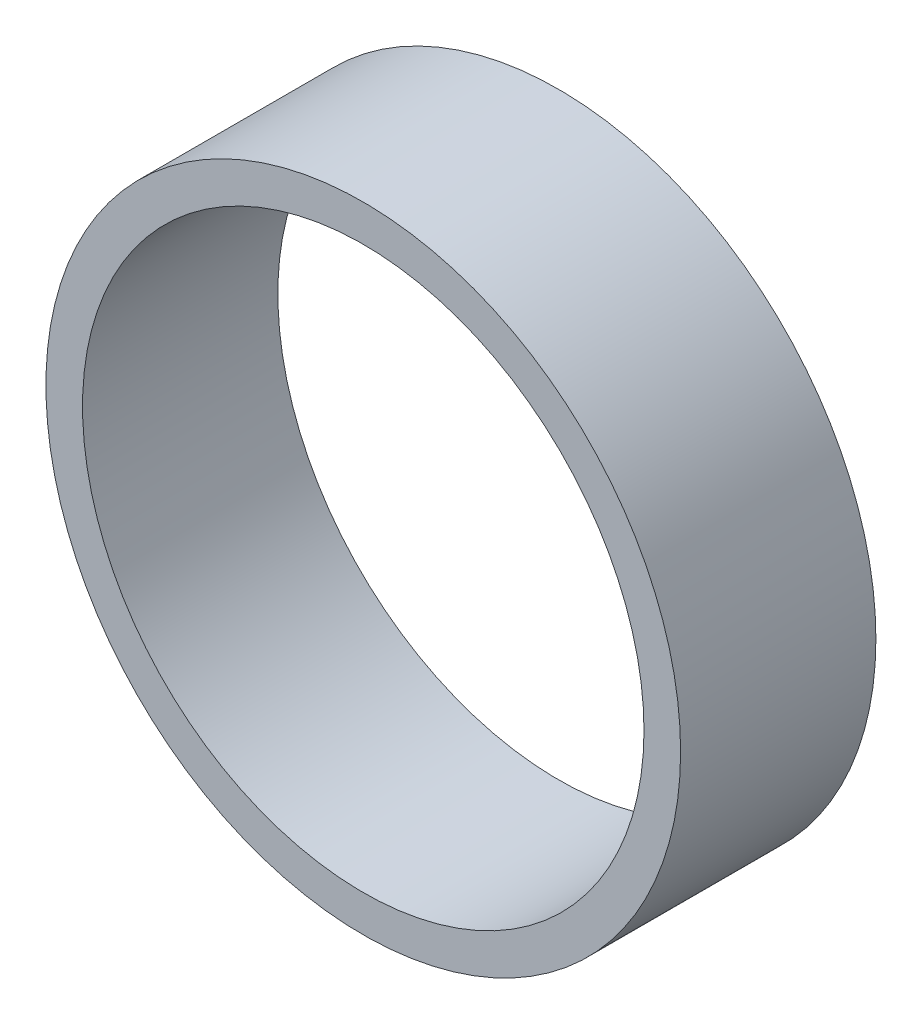
from build123d import *

# Parameters (mm, degrees)
SKETCH_1_R      = 13
SKETCH_1_R_2    = 11.5
EXTRUDE_1_DEPTH = 8


with BuildPart() as part:
    # Эскиз1 → Бобышка-Вытянуть1 (new body)
    with BuildSketch(Plane.XY):
        Circle(SKETCH_1_R)
        Circle(SKETCH_1_R_2, mode=Mode.SUBTRACT)
    extrude(amount=EXTRUDE_1_DEPTH)


solid = part.part
